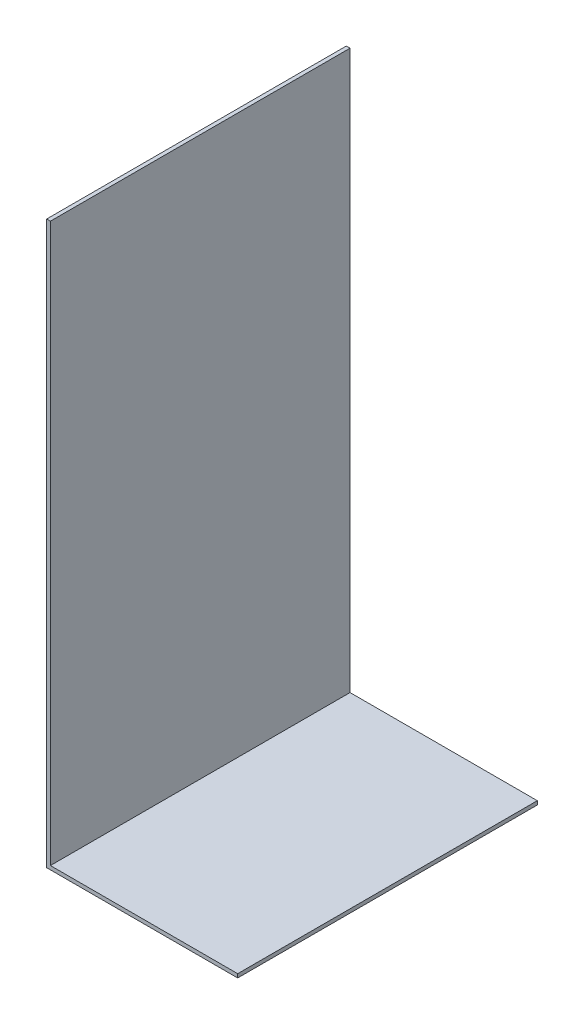
from build123d import *

# Parameters (mm, degrees)
SKETCH1_W           = 50
SKETCH1_H           = 80
BOSS_EXTRUDE1_DEPTH = 1
SKETCH3_W           = 80
SKETCH3_H           = 150
BOSS_EXTRUDE2_DEPTH = 1


with BuildPart() as part:
    # Sketch1 → Boss-Extrude1 (new body)
    with BuildSketch(Plane(origin=(0, 0, 0), x_dir=(1, 0, 0), z_dir=(0, 1, 0))):
        Rectangle(SKETCH1_W, SKETCH1_H)
    extrude(amount=BOSS_EXTRUDE1_DEPTH)

    # Sketch3 → Boss-Extrude2 (add)
    with BuildSketch(Plane.ZY.offset(25)):
        with Locations((0, 75)):
            Rectangle(SKETCH3_W, SKETCH3_H)
    extrude(amount=BOSS_EXTRUDE2_DEPTH)


solid = part.part
